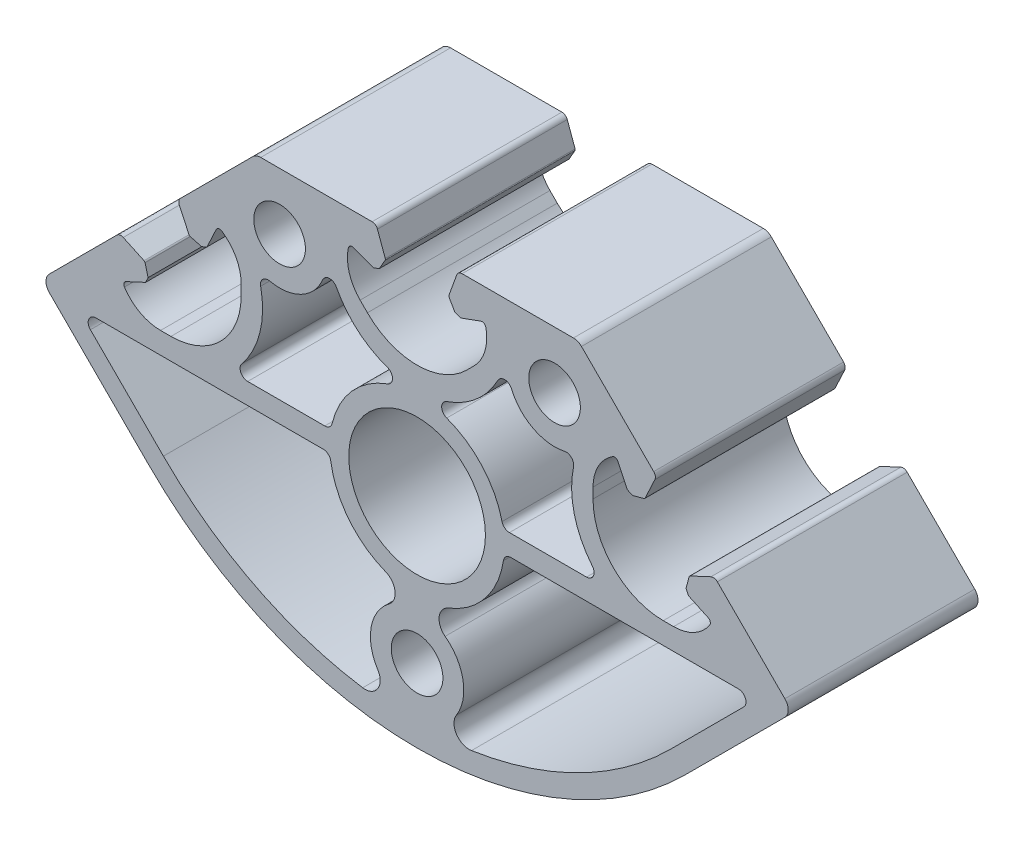
from build123d import *

# Parameters (mm, degrees)
SK_MAIN_EXTRUSION_R   = 3.4
SK_MAIN_EXTRUSION_R_2 = 9
MAIN_EXTRUSION_DEPTH  = 25


with BuildPart() as part:
    # Sk Main Extrusion → Main Extrusion (new body)
    with BuildSketch(Plane.XY):
        with BuildLine():
            Line((-35.964339765, 8.84120158), (-38.698942589, 10.116367819))
            ThreePointArc((-38.698942589, 10.116367819), (-39.146142418, 10.175242794), (-39.546236371, 9.966967065))
            Line((-39.546236371, 9.966967065), (-48.436814511, 1.076388924))
            ThreePointArc((-48.436814511, 1.076388924), (-48.876154339, 0.015728753), (-48.436814511, -1.044931419))
            Line((-48.436814511, -1.044931419), (-35.355339059, -14.126406871))
            ThreePointArc((-35.355339059, -14.126406871), (0, -28.771067812), (35.355339059, -14.126406871))
            Line((35.355339059, -14.126406871), (48.436814511, -1.044931419))
            ThreePointArc((48.436814511, -1.044931419), (48.876154339, 0.015728753), (48.436814511, 1.076388924))
            Line((48.436814511, 1.076388924), (39.546236371, 9.966967065))
            ThreePointArc((39.546236371, 9.966967065), (39.146142418, 10.175242794), (38.698942589, 10.116367819))
            Line((38.698942589, 10.116367819), (35.964339765, 8.84120158))
            ThreePointArc((35.964339765, 8.84120158), (35.87848322, 8.775321536), (35.828512874, 8.679329395))
            Line((35.828512874, 8.679329395), (35.425239457, 7.174292513))
            Line((35.425239457, 7.174292513), (35.753978107, 6.469310204))
            Line((35.753978107, 6.469310204), (38.336524222, 5.265049173))
            ThreePointArc((38.336524222, 5.265049173), (38.606308031, 4.948092133), (38.542703923, 4.53675336))
            ThreePointArc((38.542703923, 4.53675336), (36.486225813, 2.654969004), (33.783331243, 1.973371234))
            Line((33.783331243, 1.973371234), (32.420845917, 1.973371234))
            ThreePointArc((32.420845917, 1.973371234), (25.880108191, 4.682633508), (23.170845917, 11.223371234))
            Line((23.170845917, 11.223371234), (23.170845917, 12.585856559))
            ThreePointArc((23.170845917, 12.585856559), (23.852443688, 15.28875113), (25.734228043, 17.34522924))
            ThreePointArc((25.734228043, 17.34522924), (26.145566816, 17.408833348), (26.462523856, 17.139049539))
            Line((26.462523856, 17.139049539), (27.666784887, 14.556503424))
            Line((27.666784887, 14.556503424), (28.371767196, 14.227764774))
            Line((28.371767196, 14.227764774), (29.876804078, 14.631038191))
            ThreePointArc((29.876804078, 14.631038191), (29.972796219, 14.681008536), (30.038676264, 14.766865082))
            Line((30.038676264, 14.766865082), (31.313842502, 17.501467906))
            ThreePointArc((31.313842502, 17.501467906), (31.372717477, 17.948667735), (31.164441748, 18.348761688))
            Line((31.164441748, 18.348761688), (21.652543264, 27.860660172))
            ThreePointArc((21.652543264, 27.860660172), (21.165908241, 28.185819299), (20.591883092, 28.3))
            Line((20.591883092, 28.3), (5.926823816, 28.3))
            ThreePointArc((5.926823816, 28.3), (5.496641489, 28.164364033), (5.222054351, 27.806515107))
            Line((5.222054351, 27.806515107), (4.190076845, 24.971180212))
            ThreePointArc((4.190076845, 24.971180212), (4.175951325, 24.863886241), (4.208493649, 24.760675177))
            Line((4.208493649, 24.760675177), (4.987558066, 23.411296024))
            Line((4.987558066, 23.411296024), (5.718509166, 23.145251581))
            Line((5.718509166, 23.145251581), (8.396186179, 24.11984631))
            ThreePointArc((8.396186179, 24.11984631), (8.811074612, 24.086489799), (9.056960151, 23.750654467))
            ThreePointArc((9.056960151, 23.750654467), (8.933433013, 20.965882372), (7.504160339, 18.572684887))
            Line((7.504160339, 18.572684887), (6.540737726, 17.609262274))
            ThreePointArc((6.540737726, 17.609262274), (0, 14.9), (-6.540737726, 17.609262274))
            Line((-6.540737726, 17.609262274), (-7.504160339, 18.572684887))
            ThreePointArc((-7.504160339, 18.572684887), (-8.933433013, 20.965882372), (-9.056960151, 23.750654467))
            ThreePointArc((-9.056960151, 23.750654467), (-8.811074612, 24.086489799), (-8.396186179, 24.11984631))
            Line((-8.396186179, 24.11984631), (-5.718509166, 23.145251581))
            Line((-5.718509166, 23.145251581), (-4.987558066, 23.411296024))
            Line((-4.987558066, 23.411296024), (-4.208493649, 24.760675177))
            ThreePointArc((-4.208493649, 24.760675177), (-4.175951325, 24.863886241), (-4.190076845, 24.971180212))
            Line((-4.190076845, 24.971180212), (-5.222054351, 27.806515107))
            ThreePointArc((-5.222054351, 27.806515107), (-5.496641489, 28.164364033), (-5.926823816, 28.3))
            Line((-5.926823816, 28.3), (-20.591883092, 28.3))
            ThreePointArc((-20.591883092, 28.3), (-21.165908241, 28.185819299), (-21.652543264, 27.860660172))
            Line((-21.652543264, 27.860660172), (-31.164441748, 18.348761688))
            ThreePointArc((-31.164441748, 18.348761688), (-31.372717477, 17.948667735), (-31.313842502, 17.501467906))
            Line((-31.313842502, 17.501467906), (-30.038676264, 14.766865082))
            ThreePointArc((-30.038676264, 14.766865082), (-29.972796219, 14.681008536), (-29.876804078, 14.631038191))
            Line((-29.876804078, 14.631038191), (-28.371767196, 14.227764774))
            Line((-28.371767196, 14.227764774), (-27.666784887, 14.556503424))
            Line((-27.666784887, 14.556503424), (-26.462523856, 17.139049539))
            ThreePointArc((-26.462523856, 17.139049539), (-26.145566816, 17.408833348), (-25.734228043, 17.34522924))
            ThreePointArc((-25.734228043, 17.34522924), (-23.852443688, 15.28875113), (-23.170845917, 12.585856559))
            Line((-23.170845917, 12.585856559), (-23.170845917, 11.223371234))
            ThreePointArc((-23.170845917, 11.223371234), (-25.880108191, 4.682633508), (-32.420845917, 1.973371234))
            Line((-32.420845917, 1.973371234), (-33.783331243, 1.973371234))
            ThreePointArc((-33.783331243, 1.973371234), (-36.486225813, 2.654969004), (-38.542703923, 4.53675336))
            ThreePointArc((-38.542703923, 4.53675336), (-38.606308031, 4.948092133), (-38.336524222, 5.265049173))
            Line((-38.336524222, 5.265049173), (-35.753978107, 6.469310204))
            Line((-35.753978107, 6.469310204), (-35.425239457, 7.174292513))
            Line((-35.425239457, 7.174292513), (-35.828512874, 8.679329395))
            ThreePointArc((-35.828512874, 8.679329395), (-35.87848322, 8.775321536), (-35.964339765, 8.84120158))
        make_face()
        with Locations((0, -19.1)):
            Circle(SK_MAIN_EXTRUSION_R, mode=Mode.SUBTRACT)
        Circle(SK_MAIN_EXTRUSION_R_2, mode=Mode.SUBTRACT)
        with Locations((18.106601718, 20.8)):
            Circle(SK_MAIN_EXTRUSION_R, mode=Mode.SUBTRACT)
        with Locations((-18.106601718, 20.8)):
            Circle(SK_MAIN_EXTRUSION_R, mode=Mode.SUBTRACT)
        with BuildLine():
            Line((-33.410795411, -12.181863223), (-43.025551853, -2.567106781))
            ThreePointArc((-43.025551853, -2.567106781), (-43.242324604, -1.477316568), (-42.318445072, -0.86))
            Line((-42.318445072, -0.86), (-12.360841395, -0.86))
            ThreePointArc((-12.360841395, -0.86), (-11.708461138, -1.102108187), (-11.371974084, -1.7112))
            ThreePointArc((-11.371974084, -1.7112), (-8.980737669, -7.183059997), (-4.167977698, -10.718113729))
            ThreePointArc((-4.167977698, -10.718113729), (-2.911454942, -12.309920658), (-3.692145622, -14.181609948))
            ThreePointArc((-3.692145622, -14.181609948), (-6.052344462, -18.008383533), (-5.177787873, -22.418585955))
            ThreePointArc((-5.177787873, -22.418585955), (-5.184897798, -24.588029411), (-7.164897408, -25.474673081))
            ThreePointArc((-7.164897408, -25.474673081), (-21.348803489, -20.923067641), (-33.410795411, -12.181863223))
        make_face(mode=Mode.SUBTRACT)
        with BuildLine():
            Line((43.025551853, -2.567106781), (33.410795411, -12.181863223))
            ThreePointArc((33.410795411, -12.181863223), (21.348803489, -20.923067641), (7.164897408, -25.474673081))
            ThreePointArc((7.164897408, -25.474673081), (5.184897798, -24.588029411), (5.177787873, -22.418585955))
            ThreePointArc((5.177787873, -22.418585955), (6.052344462, -18.008383533), (3.692145622, -14.181609948))
            ThreePointArc((3.692145622, -14.181609948), (2.911454942, -12.309920658), (4.167977698, -10.718113729))
            ThreePointArc((4.167977698, -10.718113729), (8.980737669, -7.183059997), (11.371974084, -1.7112))
            ThreePointArc((11.371974084, -1.7112), (11.708461138, -1.102108187), (12.360841395, -0.86))
            Line((12.360841395, -0.86), (42.318445072, -0.86))
            ThreePointArc((42.318445072, -0.86), (43.242324604, -1.477316568), (43.025551853, -2.567106781))
        make_face(mode=Mode.SUBTRACT)
        with BuildLine():
            Line((22.313779306, 1.89), (12.161328052, 1.89))
            ThreePointArc((12.161328052, 1.89), (11.541328052, 2.10539819), (11.188421808, 2.6588))
            ThreePointArc((11.188421808, 2.6588), (8.576111126, 7.661613273), (3.898250872, 10.819133058))
            ThreePointArc((3.898250872, 10.819133058), (3.237253097, 11.766839243), (3.911288501, 12.70531745))
            ThreePointArc((3.911288501, 12.70531745), (7.825101881, 14.952320052), (10.632154811, 18.486072973))
            ThreePointArc((10.632154811, 18.486072973), (11.559727768, 19.021547306), (12.439624063, 18.410886302))
            ThreePointArc((12.439624063, 18.410886302), (15.272696143, 15.341842876), (19.412884455, 14.790330674))
            ThreePointArc((19.412884455, 14.790330674), (20.329585798, 14.523052251), (20.604120456, 13.608497808))
            ThreePointArc((20.604120456, 13.608497808), (20.697886834, 8.284715824), (23.085806686, 3.525589274))
            ThreePointArc((23.085806686, 3.525589274), (23.218099292, 2.463144798), (22.313779306, 1.89))
        make_face(mode=Mode.SUBTRACT)
        with BuildLine():
            Line((-12.161328052, 1.89), (-22.313779306, 1.89))
            ThreePointArc((-22.313779306, 1.89), (-23.218099292, 2.463144798), (-23.085806686, 3.525589274))
            ThreePointArc((-23.085806686, 3.525589274), (-20.697886834, 8.284715824), (-20.604120456, 13.608497808))
            ThreePointArc((-20.604120456, 13.608497808), (-20.329585798, 14.523052251), (-19.412884455, 14.790330674))
            ThreePointArc((-19.412884455, 14.790330674), (-15.272696143, 15.341842876), (-12.439624063, 18.410886302))
            ThreePointArc((-12.439624063, 18.410886302), (-11.559727768, 19.021547306), (-10.632154811, 18.486072973))
            ThreePointArc((-10.632154811, 18.486072973), (-7.825101881, 14.952320052), (-3.911288501, 12.70531745))
            ThreePointArc((-3.911288501, 12.70531745), (-3.237253097, 11.766839243), (-3.898250872, 10.819133058))
            ThreePointArc((-3.898250872, 10.819133058), (-8.576111126, 7.661613273), (-11.188421808, 2.6588))
            ThreePointArc((-11.188421808, 2.6588), (-11.541328052, 2.10539819), (-12.161328052, 1.89))
        make_face(mode=Mode.SUBTRACT)
    extrude(amount=-MAIN_EXTRUSION_DEPTH)


solid = part.part
